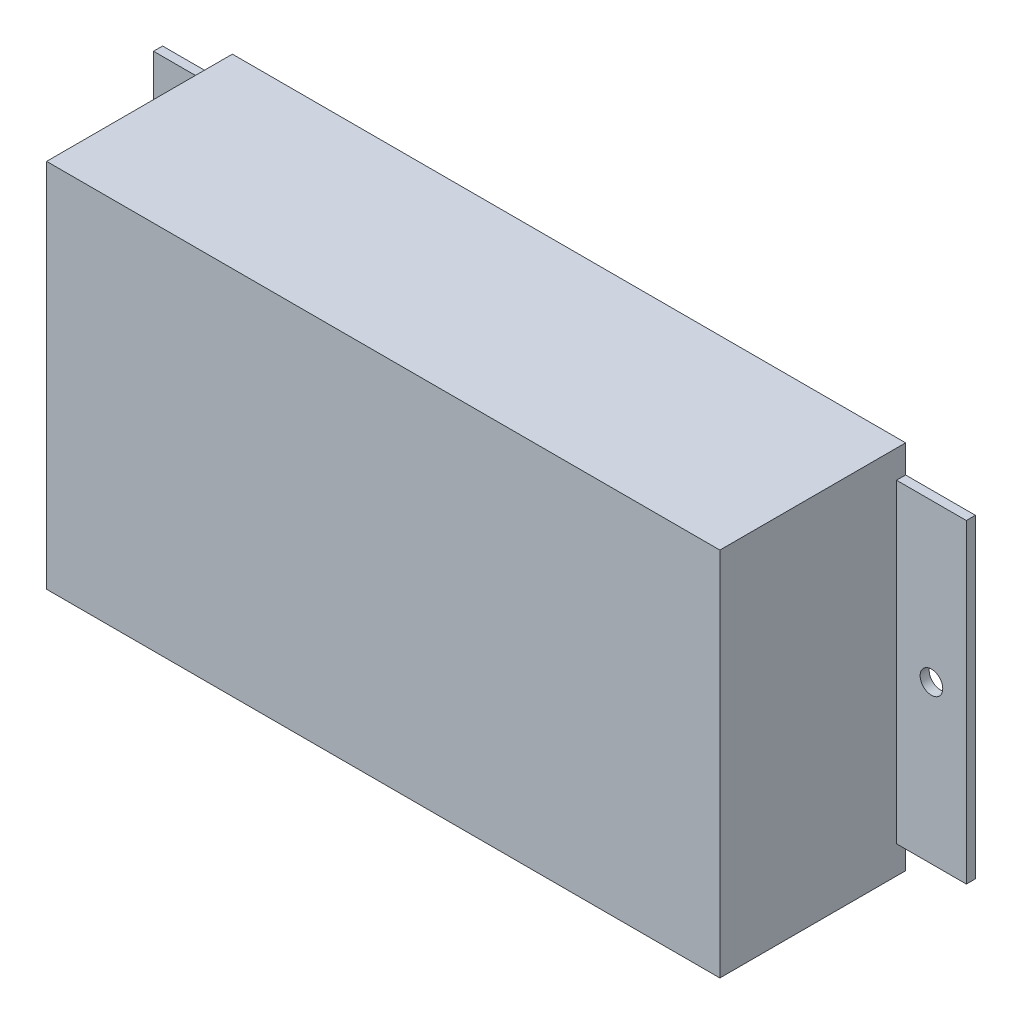
from build123d import *

# Parameters (mm, degrees)
SKETCH1_W           = 148.6
SKETCH1_H           = 81.8
BOSS_EXTRUDE1_DEPTH = 41
SKETCH2_W           = 15.4
SKETCH2_H           = 69.5
SKETCH2_R           = 2.5
BOSS_EXTRUDE2_DEPTH = 2


with BuildPart() as part:
    # Sketch1 → Boss-Extrude1 (new body)
    with BuildSketch(Plane.XY):
        with Locations((74.3, -40.9)):
            Rectangle(SKETCH1_W, SKETCH1_H)
    extrude(amount=BOSS_EXTRUDE1_DEPTH)

    # Sketch2 → Boss-Extrude2 (add)
    with BuildSketch(Plane(origin=(0, 0, 0), x_dir=(-1, 0, 0), z_dir=(0, 0, -1))):
        with Locations((7.7, -40.9)):
            Rectangle(SKETCH2_W, SKETCH2_H)
        with Locations((7.7, -40.9)):
            Circle(SKETCH2_R, mode=Mode.SUBTRACT)
        with Locations((-156.3, -40.9)):
            Rectangle(SKETCH2_W, SKETCH2_H)
        with Locations((-156.3, -40.9)):
            Circle(SKETCH2_R, mode=Mode.SUBTRACT)
    extrude(amount=-BOSS_EXTRUDE2_DEPTH)


solid = part.part
